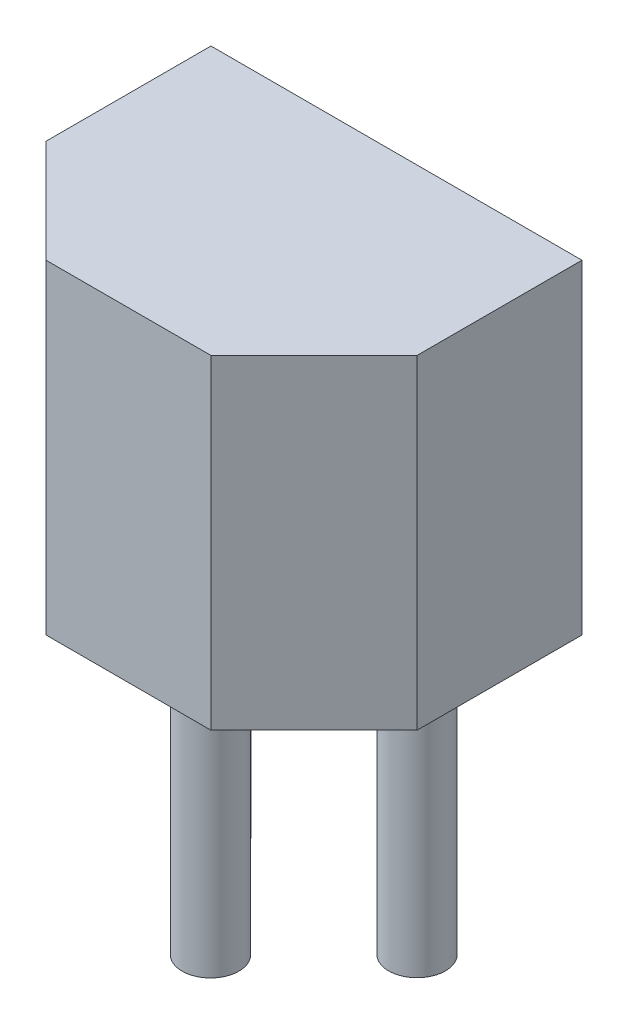
from build123d import *

# Parameters (mm, degrees)
BOSS_EXTRUDE1_DEPTH = 4
SKETCH2_R           = 0.35
BOSS_EXTRUDE2_DEPTH = 3.41


with BuildPart() as part:
    # Sketch1 → Boss-Extrude1 (new body)
    with BuildSketch(Plane(origin=(0, 0, 0), x_dir=(1, 0, 0), z_dir=(0, 1, 0))):
        Polygon((-1.016, -1.016), (0.254, -2.286), (2.286, -2.286), (3.556, -1.016), (3.556, 1.016), (-1.016, 1.016), align=None)
    extrude(amount=BOSS_EXTRUDE1_DEPTH)

    # Sketch2 → Boss-Extrude2 (add)
    with BuildSketch(Plane.XZ):
        Circle(SKETCH2_R)
        with Locations((2.54, 0)):
            Circle(SKETCH2_R)
        with Locations((1.27, 1.2755783)):
            Circle(SKETCH2_R)
    extrude(amount=BOSS_EXTRUDE2_DEPTH)


solid = part.part
